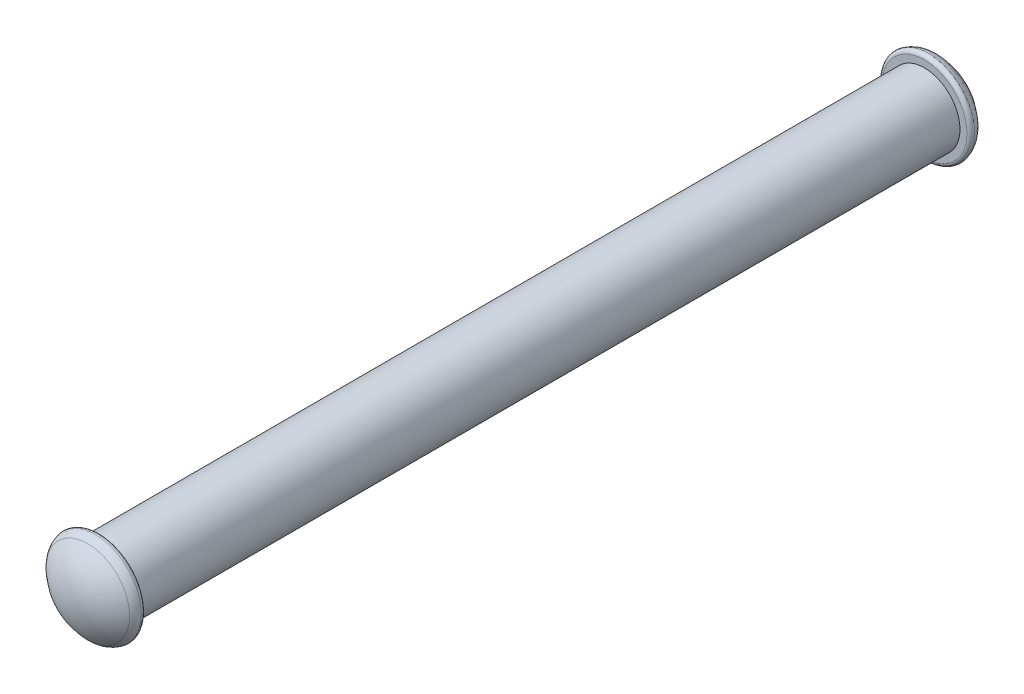
from build123d import *

# Parameters (mm, degrees)
SKETCH1_R                  = 0.5
BOSS_EXTRUDE1_DEPTH        = 5.8
SKETCH2_R                  = 0.65
BOSS_EXTRUDE2_DEPTH        = 0.1
DOME1_FACE_RADIUS          = 0.65
DOME1_HEIGHT               = 0.3
FILLET1_R                  = 0.2
FILLET3_R                  = 0.05
MIRROR2_COPY_1_FACE_RADIUS = 0.65
MIRROR2_COPY_1_HEIGHT      = 0.3
FILLET1_OF_MIRROR2_R       = 0.2
FILLET3_OF_MIRROR2_R       = 0.05


with BuildPart() as part:
    # Sketch1 → Boss-Extrude1 (new, symmetric)
    with BuildSketch(Plane.XY):
        Circle(SKETCH1_R)
    extrude(amount=BOSS_EXTRUDE1_DEPTH, both=True)

    # Sketch2 → Boss-Extrude2 (add)
    with BuildSketch(Plane.XY.offset(5.8)):
        Circle(SKETCH2_R)
    boss_extrude2 = extrude(amount=BOSS_EXTRUDE2_DEPTH)

    # Dome1: a dome of height H over a round flat face of radius A is a cap of a sphere of radius (A * A + H * H) / (2 * H)
    dome1_r = (DOME1_FACE_RADIUS * DOME1_FACE_RADIUS + DOME1_HEIGHT * DOME1_HEIGHT) / (2 * DOME1_HEIGHT)
    dome1_base = Plane((0, 0, 5.9), z_dir=(0, 0, 1))
    with Locations(dome1_base.offset(DOME1_HEIGHT - dome1_r)):
        dome1_ball = Sphere(dome1_r, mode=Mode.PRIVATE)
    add(split(dome1_ball, bisect_by=dome1_base, keep=Keep.TOP, mode=Mode.PRIVATE))

    # Fillet1
    fillet1_edges = [part.edges().sort_by_distance(p)[0] for p in [
        (-0.65, 0, 5.9),
    ]]
    fillet(fillet1_edges, radius=FILLET1_R)

    # Fillet3
    fillet3_edges = [part.edges().sort_by_distance(p)[0] for p in [
        (-0.65, 0, 5.8),
    ]]
    fillet(fillet3_edges, radius=FILLET3_R)

    # Mirror2: Boss-Extrude2 across plane
    add(boss_extrude2.mirror(Plane.XY))

    # Mirror2 copy 1: a dome of height H over a round flat face of radius A is a cap of a sphere of radius (A * A + H * H) / (2 * H)
    mirror2_copy_1_r = (MIRROR2_COPY_1_FACE_RADIUS * MIRROR2_COPY_1_FACE_RADIUS + MIRROR2_COPY_1_HEIGHT * MIRROR2_COPY_1_HEIGHT) / (2 * MIRROR2_COPY_1_HEIGHT)
    mirror2_copy_1_base = Plane((0, 0, -5.9), z_dir=(0, 0, -1))
    with Locations(mirror2_copy_1_base.offset(MIRROR2_COPY_1_HEIGHT - mirror2_copy_1_r)):
        mirror2_copy_1_ball = Sphere(mirror2_copy_1_r, mode=Mode.PRIVATE)
    add(split(mirror2_copy_1_ball, bisect_by=mirror2_copy_1_base, keep=Keep.TOP, mode=Mode.PRIVATE))

    # Fillet1 of Mirror2
    fillet1_of_mirror2_edges = [part.edges().sort_by_distance(p)[0] for p in [
        (-0.65, 0, -5.9),
    ]]
    fillet(fillet1_of_mirror2_edges, radius=FILLET1_OF_MIRROR2_R)

    # Fillet3 of Mirror2
    fillet3_of_mirror2_edges = [part.edges().sort_by_distance(p)[0] for p in [
        (-0.65, 0, -5.8),
    ]]
    fillet(fillet3_of_mirror2_edges, radius=FILLET3_OF_MIRROR2_R)


solid = part.part
